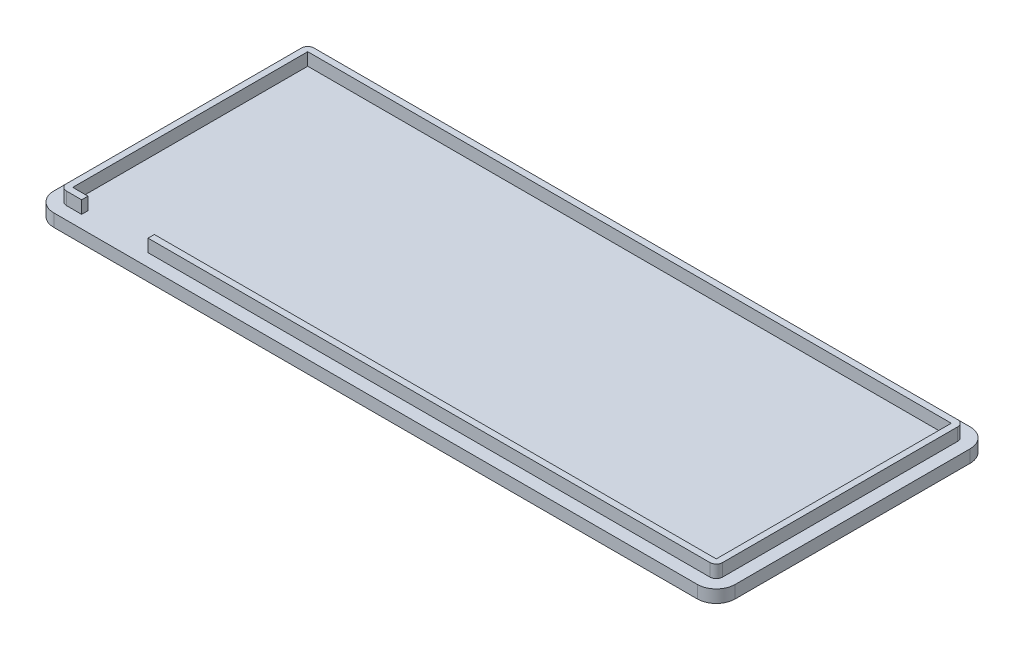
from build123d import *

# Parameters (mm, degrees)
BOSS_EXTRUDE1_DEPTH = 2
SKETCH2_W           = 102
SKETCH2_H           = 37.25
BOSS_EXTRUDE2_DEPTH = 2
SKETCH3_W           = 10.5265
SKETCH3_H           = 3.907167626
CUT_EXTRUDE1_DEPTH  = 2


with BuildPart() as part:
    # Sketch1 → Boss-Extrude1 (new body)
    with BuildSketch(Plane(origin=(0, 0, 0), x_dir=(1, 0, 0), z_dir=(0, 1, 0))):
        with BuildLine():
            Line((51, -21.625), (-51, -21.625))
            ThreePointArc((-51, -21.625), (-53.121320344, -20.746320344), (-54, -18.625))
            Line((-54, -18.625), (-54, 18.625))
            ThreePointArc((-54, 18.625), (-53.121320344, 20.746320344), (-51, 21.625))
            Line((-51, 21.625), (51, 21.625))
            ThreePointArc((51, 21.625), (53.121320344, 20.746320344), (54, 18.625))
            Line((54, 18.625), (54, -18.625))
            ThreePointArc((54, -18.625), (53.121320344, -20.746320344), (51, -21.625))
        make_face()
    extrude(amount=BOSS_EXTRUDE1_DEPTH)

    # Sketch2 → Boss-Extrude2 (add)
    with BuildSketch(Plane(origin=(0, 2, 0), x_dir=(1, 0, 0), z_dir=(0, 1, 0))):
        with BuildLine():
            Line((51, -19.625), (-51, -19.625))
            ThreePointArc((-51, -19.625), (-51.707106781, -19.332106781), (-52, -18.625))
            Line((-52, -18.625), (-52, 18.625))
            ThreePointArc((-52, 18.625), (-51.707106781, 19.332106781), (-51, 19.625))
            Line((-51, 19.625), (51, 19.625))
            ThreePointArc((51, 19.625), (51.707106781, 19.332106781), (52, 18.625))
            Line((52, 18.625), (52, -18.625))
            ThreePointArc((52, -18.625), (51.707106781, -19.332106781), (51, -19.625))
        make_face()
        Rectangle(SKETCH2_W, SKETCH2_H, mode=Mode.SUBTRACT)
    extrude(amount=BOSS_EXTRUDE2_DEPTH)

    # Sketch3 → Cut-Extrude1 (cut)
    with BuildSketch(Plane.XY.offset(19.625)):
        with Locations((-43.32145, 3.953583813)):
            Rectangle(SKETCH3_W, SKETCH3_H)
    extrude(amount=-CUT_EXTRUDE1_DEPTH, mode=Mode.SUBTRACT)


solid = part.part
